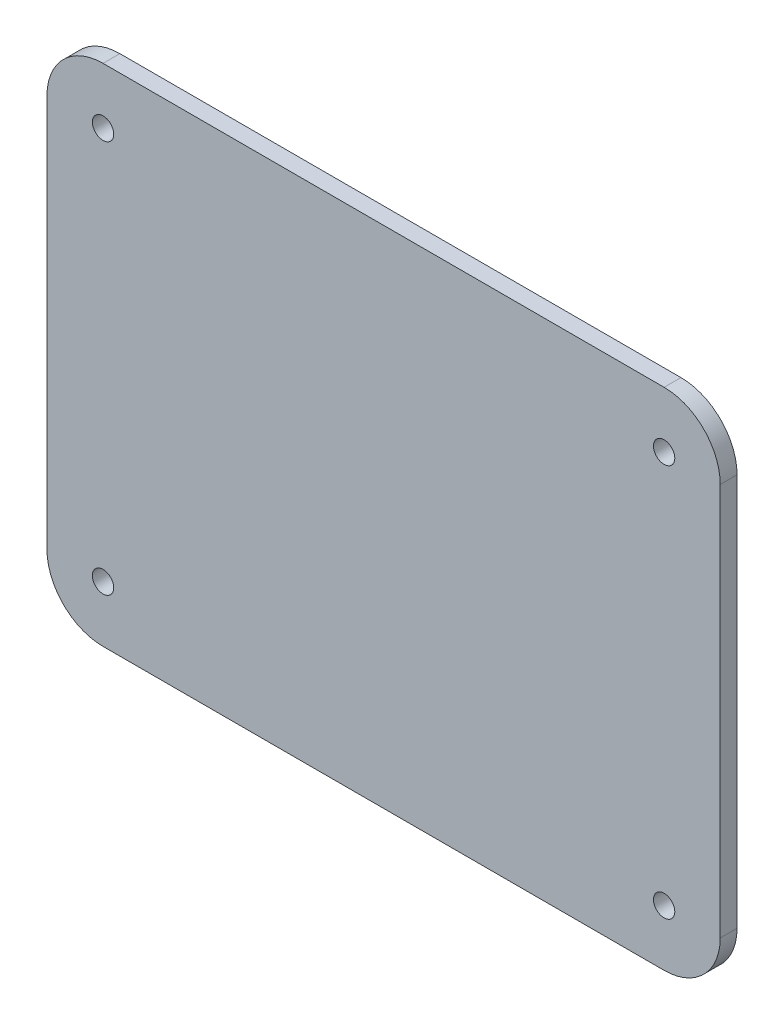
from build123d import *

# Parameters (mm, degrees)
SKETCH3_R           = 1.9
BOSS_EXTRUDE2_DEPTH = 3


with BuildPart() as part:
    # Sketch3 → Boss-Extrude2 (new body)
    with BuildSketch(Plane.XY):
        with BuildLine():
            Line((-50, 45), (50, 45))
            ThreePointArc((50, 45), (57.071067812, 42.071067812), (60, 35))
            Line((60, 35), (60, -35))
            ThreePointArc((60, -35), (57.071067812, -42.071067812), (50, -45))
            Line((50, -45), (-50, -45))
            ThreePointArc((-50, -45), (-57.071067812, -42.071067812), (-60, -35))
            Line((-60, -35), (-60, 35))
            ThreePointArc((-60, 35), (-57.071067812, 42.071067812), (-50, 45))
        make_face()
        with Locations((-50, 35)):
            Circle(SKETCH3_R, mode=Mode.SUBTRACT)
        with Locations((50, 35)):
            Circle(SKETCH3_R, mode=Mode.SUBTRACT)
        with Locations((50, -35)):
            Circle(SKETCH3_R, mode=Mode.SUBTRACT)
        with Locations((-50, -35)):
            Circle(SKETCH3_R, mode=Mode.SUBTRACT)
    extrude(amount=BOSS_EXTRUDE2_DEPTH)


solid = part.part
